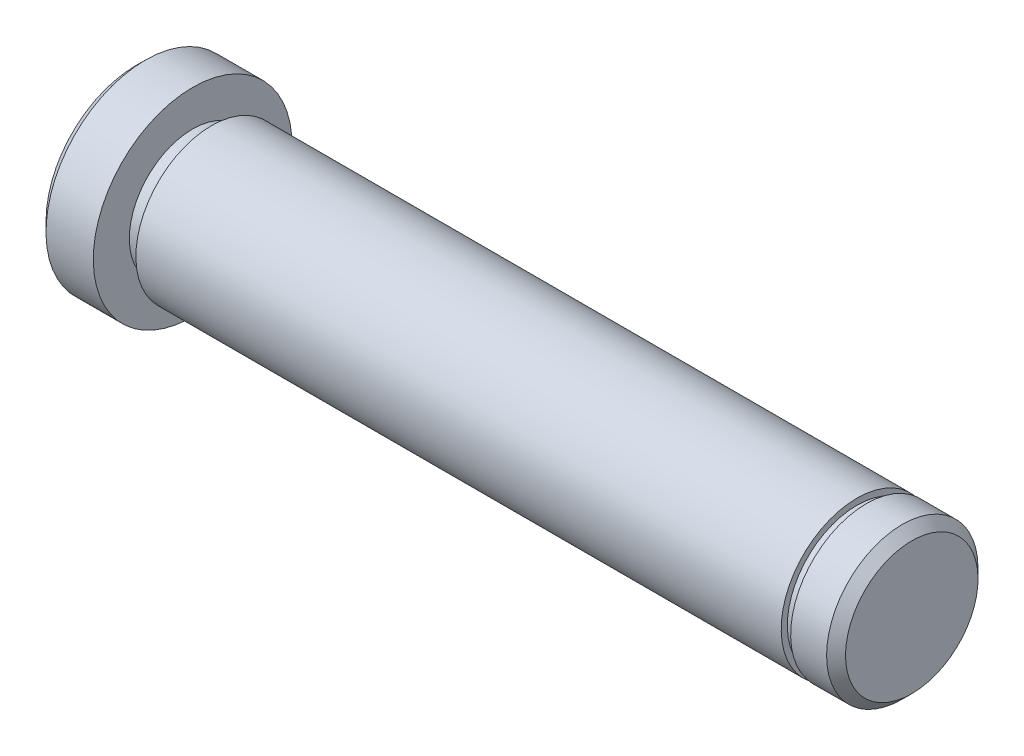
from build123d import *

# Parameters (mm, degrees)
CHAMFER_1_SIZE = 1


with BuildPart() as part:
    # 草图1 → 旋转1 (revolve)
    with BuildSketch(Plane.XY):
        Polygon((0, 10.5), (0, 0), (82, 0), (82, 8), (77.2, 8), (77.2, 7.35), (76.2, 7.35), (76.2, 8), (8, 8), (8, 6.691876128), (6, 6.691876128), (6, 8), (6, 10.5), align=None)
    revolve(axis=Axis((82, 0, 0), (-1, 0, 0)))

    # 倒角1
    chamfer_1_edges = [part.edges().sort_by_distance(p)[0] for p in [
        (82, -8, 0),
        (0, -10.5, 0),
    ]]
    chamfer(chamfer_1_edges, length=CHAMFER_1_SIZE)


solid = part.part
